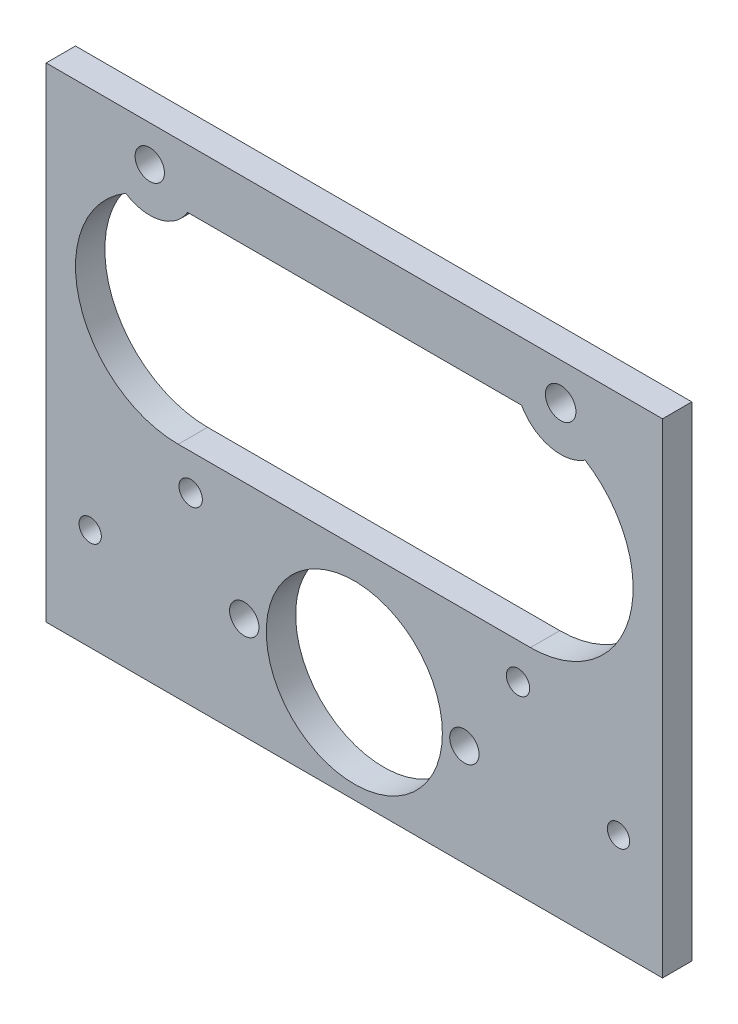
from build123d import *

# Parameters (mm, degrees)
SKETCH1_W           = 133.35
SKETCH1_H           = 104.775
SKETCH1_R           = 2.413
SKETCH1_R_2         = 2.5273
SKETCH1_R_3         = 3.175
SKETCH1_R_4         = 19.05
SKETCH1_R_5         = 3.302
BOSS_EXTRUDE1_DEPTH = 6.35


with BuildPart() as part:
    # Sketch1 → Boss-Extrude1 (new body)
    with BuildSketch(Plane.XY):
        with Locations((0, 30.353)):
            Rectangle(SKETCH1_W, SKETCH1_H)
        with Locations((-57.15, 0)):
            Circle(SKETCH1_R, mode=Mode.SUBTRACT)
        with Locations((-35.41150672, 17.8308)):
            Circle(SKETCH1_R_2, mode=Mode.SUBTRACT)
        with Locations((-23.8125, 0)):
            Circle(SKETCH1_R_3, mode=Mode.SUBTRACT)
        Circle(SKETCH1_R_4, mode=Mode.SUBTRACT)
        with Locations((23.8125, 0)):
            Circle(SKETCH1_R_3, mode=Mode.SUBTRACT)
        with Locations((35.41150672, 17.8308)):
            Circle(SKETCH1_R_2, mode=Mode.SUBTRACT)
        with Locations((57.15, 0)):
            Circle(SKETCH1_R, mode=Mode.SUBTRACT)
        with Locations((44.64152658, 74.693330266)):
            Circle(SKETCH1_R_5, mode=Mode.SUBTRACT)
        with Locations((-44.258181609, 74.921110792)):
            Circle(SKETCH1_R_3, mode=Mode.SUBTRACT)
        with BuildLine():
            Line((-36.078617849, 70.0405), (36.185033541, 70.0405))
            ThreePointArc((36.185033541, 70.0405), (42.31521137, 65.325867347), (49.938818951, 66.624885711))
            ThreePointArc((49.938818951, 66.624885711), (59.454030327, 41.654654783), (38.1, 25.5905))
            Line((38.1, 25.5905), (-38.1, 25.5905))
            ThreePointArc((-38.1, 25.5905), (-59.533112769, 41.9356784), (-49.440641566, 66.929381706))
            ThreePointArc((-49.440641566, 66.929381706), (-42.098222799, 65.644246939), (-36.078617849, 70.0405))
        make_face(mode=Mode.SUBTRACT)
    extrude(amount=-BOSS_EXTRUDE1_DEPTH)


solid = part.part
